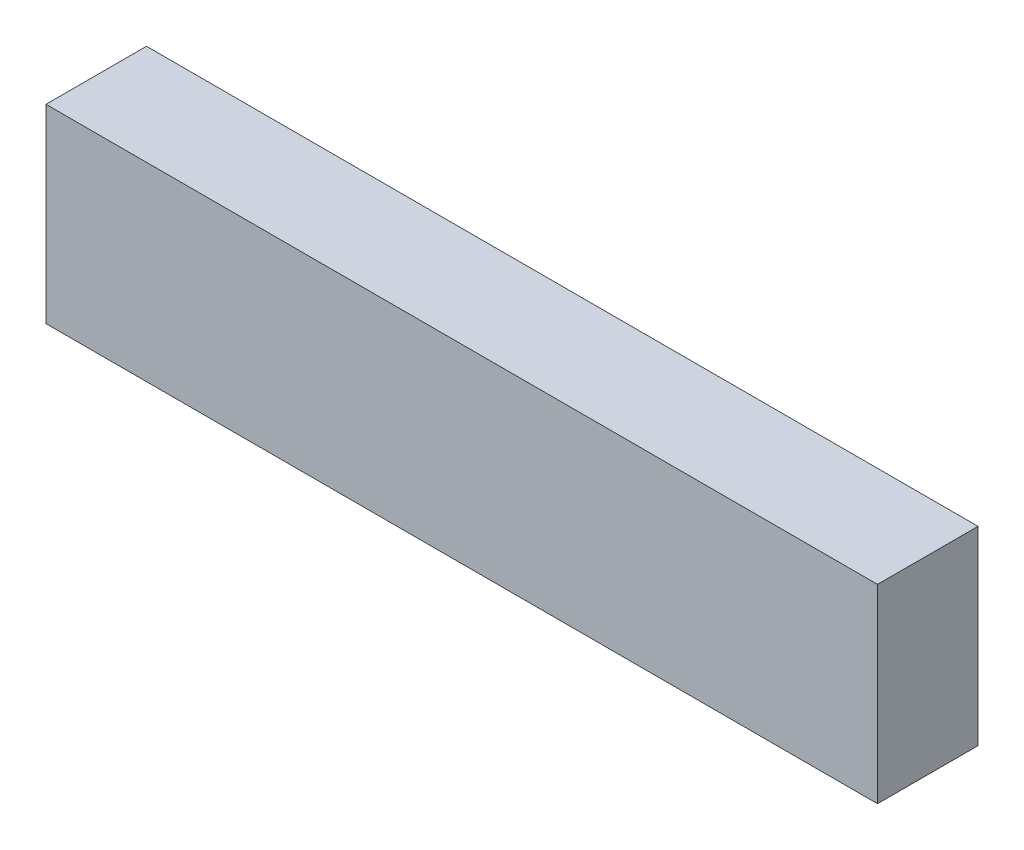
from build123d import *

# Parameters (mm, degrees)
SKETCH_1_W      = 60.4
SKETCH_1_H      = 13.8
EXTRUDE_1_DEPTH = 7.3


with BuildPart() as part:
    # Эскиз1 → Бобышка-Вытянуть1 (new body)
    with BuildSketch(Plane.XY):
        Rectangle(SKETCH_1_W, SKETCH_1_H)
    extrude(amount=EXTRUDE_1_DEPTH)


solid = part.part
